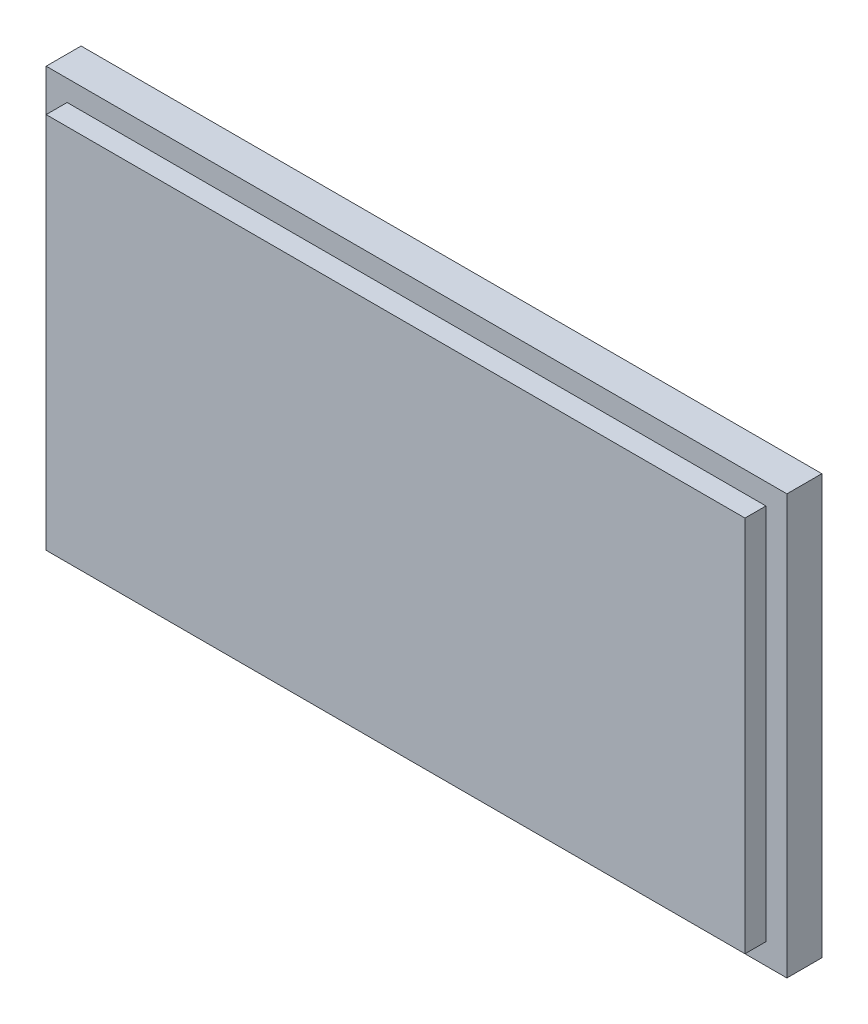
from build123d import *

# Parameters (mm, degrees)
SKETCH1_W           = 53
SKETCH1_H           = 30
BOSS_EXTRUDE1_DEPTH = 4
SKETCH2_OUTSIDE_W   = 67.206
SKETCH2_OUTSIDE_H   = 44.206
SKETCH2_OUTSIDE_W_2 = 50
SKETCH2_OUTSIDE_H_2 = 27
CUT_EXTRUDE1_DEPTH  = 1.5


with BuildPart() as part:
    # Sketch1 → Boss-Extrude1 (new body)
    with BuildSketch(Plane.XY):
        Rectangle(SKETCH1_W, SKETCH1_H)
    extrude(amount=BOSS_EXTRUDE1_DEPTH)

    # Sketch2 outside → Cut-Extrude1 (cut)
    with BuildSketch(Plane.XY.offset(4)):
        Rectangle(SKETCH2_OUTSIDE_W, SKETCH2_OUTSIDE_H)
        Rectangle(SKETCH2_OUTSIDE_W_2, SKETCH2_OUTSIDE_H_2, mode=Mode.SUBTRACT)
    extrude(amount=-CUT_EXTRUDE1_DEPTH, mode=Mode.SUBTRACT)


solid = part.part
